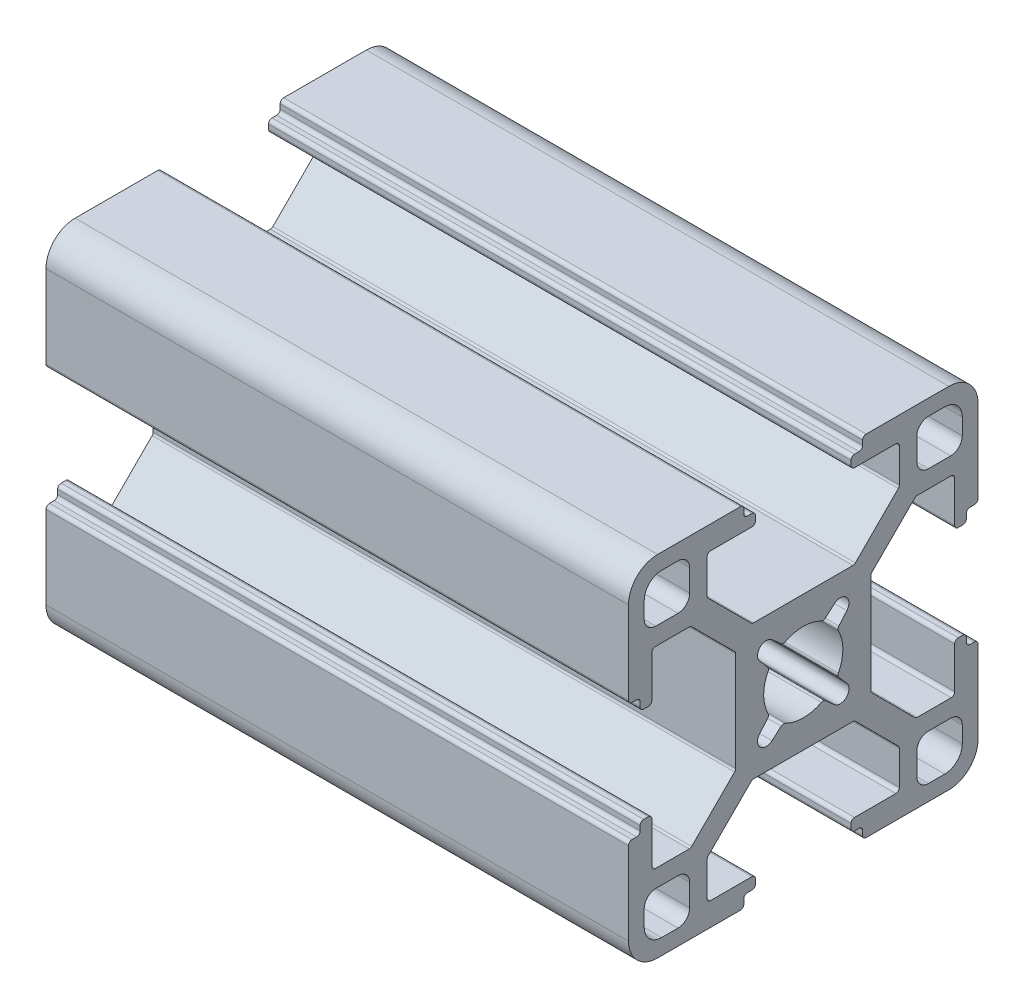
from build123d import *

# Parameters (mm, degrees)
BOSS_EXTRUDE1_DEPTH = 50


with BuildPart() as part:
    # Sketch1 → Boss-Extrude1 (new body)
    with BuildSketch(Plane(origin=(0, 0, 0), x_dir=(0, 0, -1), z_dir=(1, 0, 0))):
        with BuildLine():
            Line((-8.25, 9.788477631), (-8.25, 12.7))
            ThreePointArc((-8.25, 12.7), (-8.162132034, 12.912132034), (-7.95, 13))
            Line((-7.95, 13), (-4.4, 13))
            ThreePointArc((-4.4, 13), (-4.187867966, 13.087867966), (-4.1, 13.3))
            Line((-4.1, 13.3), (-4.1, 13.7))
            ThreePointArc((-4.1, 13.7), (-4.187867966, 13.912132034), (-4.4, 14))
            Line((-4.4, 14), (-4.8, 14))
            ThreePointArc((-4.8, 14), (-5.012132034, 14.087867966), (-5.1, 14.3))
            Line((-5.1, 14.3), (-5.1, 14.7))
            ThreePointArc((-5.1, 14.7), (-5.187867966, 14.912132034), (-5.4, 15))
            Line((-5.4, 15), (-12.5, 15))
            ThreePointArc((-12.5, 15), (-14.267766953, 14.267766953), (-15, 12.5))
            Line((-15, 12.5), (-15, 5.4))
            ThreePointArc((-15, 5.4), (-14.912132034, 5.187867966), (-14.7, 5.1))
            Line((-14.7, 5.1), (-14.3, 5.1))
            ThreePointArc((-14.3, 5.1), (-14.087867966, 5.012132034), (-14, 4.8))
            Line((-14, 4.8), (-14, 4.4))
            ThreePointArc((-14, 4.4), (-13.912132034, 4.187867966), (-13.7, 4.1))
            Line((-13.7, 4.1), (-13.3, 4.1))
            ThreePointArc((-13.3, 4.1), (-13.087867966, 4.187867966), (-13, 4.4))
            Line((-13, 4.4), (-13, 7.95))
            ThreePointArc((-13, 7.95), (-12.912132034, 8.162132034), (-12.7, 8.25))
            Line((-12.7, 8.25), (-9.788477631, 8.25))
            ThreePointArc((-9.788477631, 8.25), (-9.673672601, 8.22716386), (-9.576345597, 8.162132034))
            Line((-9.576345597, 8.162132034), (-5.887867966, 4.473654403))
            ThreePointArc((-5.887867966, 4.473654403), (-5.82283614, 4.376327399), (-5.8, 4.261522369))
            Line((-5.8, 4.261522369), (-5.8, -4.261522369))
            ThreePointArc((-5.8, -4.261522369), (-5.82283614, -4.376327399), (-5.887867966, -4.473654403))
            Line((-5.887867966, -4.473654403), (-9.576345597, -8.162132034))
            ThreePointArc((-9.576345597, -8.162132034), (-9.673672601, -8.22716386), (-9.788477631, -8.25))
            Line((-9.788477631, -8.25), (-12.7, -8.25))
            ThreePointArc((-12.7, -8.25), (-12.912132034, -8.162132034), (-13, -7.95))
            Line((-13, -7.95), (-13, -4.4))
            ThreePointArc((-13, -4.4), (-13.087867966, -4.187867966), (-13.3, -4.1))
            Line((-13.3, -4.1), (-13.7, -4.1))
            ThreePointArc((-13.7, -4.1), (-13.912132034, -4.187867966), (-14, -4.4))
            Line((-14, -4.4), (-14, -4.8))
            ThreePointArc((-14, -4.8), (-14.087867966, -5.012132034), (-14.3, -5.1))
            Line((-14.3, -5.1), (-14.7, -5.1))
            ThreePointArc((-14.7, -5.1), (-14.912132034, -5.187867966), (-15, -5.4))
            Line((-15, -5.4), (-15, -12.5))
            ThreePointArc((-15, -12.5), (-14.267766953, -14.267766953), (-12.5, -15))
            Line((-12.5, -15), (-5.4, -15))
            ThreePointArc((-5.4, -15), (-5.187867966, -14.912132034), (-5.1, -14.7))
            Line((-5.1, -14.7), (-5.1, -14.3))
            ThreePointArc((-5.1, -14.3), (-5.012132034, -14.087867966), (-4.8, -14))
            Line((-4.8, -14), (-4.4, -14))
            ThreePointArc((-4.4, -14), (-4.187867966, -13.912132034), (-4.1, -13.7))
            Line((-4.1, -13.7), (-4.1, -13.3))
            ThreePointArc((-4.1, -13.3), (-4.187867966, -13.087867966), (-4.4, -13))
            Line((-4.4, -13), (-7.95, -13))
            ThreePointArc((-7.95, -13), (-8.162132034, -12.912132034), (-8.25, -12.7))
            Line((-8.25, -12.7), (-8.25, -9.788477631))
            ThreePointArc((-8.25, -9.788477631), (-8.22716386, -9.673672601), (-8.162132034, -9.576345597))
            Line((-8.162132034, -9.576345597), (-4.473654403, -5.887867966))
            ThreePointArc((-4.473654403, -5.887867966), (-4.376327399, -5.82283614), (-4.261522369, -5.8))
            Line((-4.261522369, -5.8), (4.261522369, -5.8))
            ThreePointArc((4.261522369, -5.8), (4.376327399, -5.82283614), (4.473654403, -5.887867966))
            Line((4.473654403, -5.887867966), (8.162132034, -9.576345597))
            ThreePointArc((8.162132034, -9.576345597), (8.22716386, -9.673672601), (8.25, -9.788477631))
            Line((8.25, -9.788477631), (8.25, -12.7))
            ThreePointArc((8.25, -12.7), (8.162132034, -12.912132034), (7.95, -13))
            Line((7.95, -13), (4.4, -13))
            ThreePointArc((4.4, -13), (4.187867966, -13.087867966), (4.1, -13.3))
            Line((4.1, -13.3), (4.1, -13.7))
            ThreePointArc((4.1, -13.7), (4.187867966, -13.912132034), (4.4, -14))
            Line((4.4, -14), (4.8, -14))
            ThreePointArc((4.8, -14), (5.012132034, -14.087867966), (5.1, -14.3))
            Line((5.1, -14.3), (5.1, -14.7))
            ThreePointArc((5.1, -14.7), (5.187867966, -14.912132034), (5.4, -15))
            Line((5.4, -15), (12.5, -15))
            ThreePointArc((12.5, -15), (14.267766953, -14.267766953), (15, -12.5))
            Line((15, -12.5), (15, -5.4))
            ThreePointArc((15, -5.4), (14.912132034, -5.187867966), (14.7, -5.1))
            Line((14.7, -5.1), (14.3, -5.1))
            ThreePointArc((14.3, -5.1), (14.087867966, -5.012132034), (14, -4.8))
            Line((14, -4.8), (14, -4.4))
            ThreePointArc((14, -4.4), (13.912132034, -4.187867966), (13.7, -4.1))
            Line((13.7, -4.1), (13.3, -4.1))
            ThreePointArc((13.3, -4.1), (13.087867966, -4.187867966), (13, -4.4))
            Line((13, -4.4), (13, -7.95))
            ThreePointArc((13, -7.95), (12.912132034, -8.162132034), (12.7, -8.25))
            Line((12.7, -8.25), (9.788477631, -8.25))
            ThreePointArc((9.788477631, -8.25), (9.673672601, -8.22716386), (9.576345597, -8.162132034))
            Line((9.576345597, -8.162132034), (5.887867966, -4.473654403))
            ThreePointArc((5.887867966, -4.473654403), (5.82283614, -4.376327399), (5.8, -4.261522369))
            Line((5.8, -4.261522369), (5.8, 4.261522369))
            ThreePointArc((5.8, 4.261522369), (5.82283614, 4.376327399), (5.887867966, 4.473654403))
            Line((5.887867966, 4.473654403), (9.576345597, 8.162132034))
            ThreePointArc((9.576345597, 8.162132034), (9.673672601, 8.22716386), (9.788477631, 8.25))
            Line((9.788477631, 8.25), (12.7, 8.25))
            ThreePointArc((12.7, 8.25), (12.912132034, 8.162132034), (13, 7.95))
            Line((13, 7.95), (13, 4.4))
            ThreePointArc((13, 4.4), (13.087867966, 4.187867966), (13.3, 4.1))
            Line((13.3, 4.1), (13.7, 4.1))
            ThreePointArc((13.7, 4.1), (13.912132034, 4.187867966), (14, 4.4))
            Line((14, 4.4), (14, 4.8))
            ThreePointArc((14, 4.8), (14.087867966, 5.012132034), (14.3, 5.1))
            Line((14.3, 5.1), (14.7, 5.1))
            ThreePointArc((14.7, 5.1), (14.912132034, 5.187867966), (15, 5.4))
            Line((15, 5.4), (15, 12.5))
            ThreePointArc((15, 12.5), (14.267766953, 14.267766953), (12.5, 15))
            Line((12.5, 15), (5.4, 15))
            ThreePointArc((5.4, 15), (5.187867966, 14.912132034), (5.1, 14.7))
            Line((5.1, 14.7), (5.1, 14.3))
            ThreePointArc((5.1, 14.3), (5.012132034, 14.087867966), (4.8, 14))
            Line((4.8, 14), (4.4, 14))
            ThreePointArc((4.4, 14), (4.187867966, 13.912132034), (4.1, 13.7))
            Line((4.1, 13.7), (4.1, 13.3))
            ThreePointArc((4.1, 13.3), (4.187867966, 13.087867966), (4.4, 13))
            Line((4.4, 13), (7.95, 13))
            ThreePointArc((7.95, 13), (8.162132034, 12.912132034), (8.25, 12.7))
            Line((8.25, 12.7), (8.25, 9.788477631))
            ThreePointArc((8.25, 9.788477631), (8.22716386, 9.673672601), (8.162132034, 9.576345597))
            Line((8.162132034, 9.576345597), (4.473654403, 5.887867966))
            ThreePointArc((4.473654403, 5.887867966), (4.376327399, 5.82283614), (4.261522369, 5.8))
            Line((4.261522369, 5.8), (-4.261522369, 5.8))
            ThreePointArc((-4.261522369, 5.8), (-4.376327399, 5.82283614), (-4.473654403, 5.887867966))
            Line((-4.473654403, 5.887867966), (-8.162132034, 9.576345597))
            ThreePointArc((-8.162132034, 9.576345597), (-8.22716386, 9.673672601), (-8.25, 9.788477631))
        make_face()
        with BuildLine():
            Line((3.05514787, -1.904659815), (3.741964502, -2.698343541))
            ThreePointArc((3.741964502, -2.698343541), (3.70396732, -3.720635173), (2.68151539, -3.75404201))
            Line((2.68151539, -3.75404201), (1.890923385, -3.06366876))
            ThreePointArc((1.890923385, -3.06366876), (1.729867527, -2.991839768), (1.556279141, -3.022911715))
            ThreePointArc((1.556279141, -3.022911715), (0, -3.4), (-1.55627914, -3.022911715))
            ThreePointArc((-1.55627914, -3.022911715), (-1.729867526, -2.991839768), (-1.890923385, -3.06366876))
            Line((-1.890923385, -3.06366876), (-2.68151539, -3.75404201))
            ThreePointArc((-2.68151539, -3.75404201), (-3.70396732, -3.720635173), (-3.741964502, -2.698343541))
            Line((-3.741964502, -2.698343541), (-3.05514787, -1.904659815))
            ThreePointArc((-3.05514787, -1.904659815), (-2.984042722, -1.743283077), (-3.015893746, -1.56983595))
            ThreePointArc((-3.015893746, -1.56983595), (-3.4, 0), (-3.015893746, 1.56983595))
            ThreePointArc((-3.015893746, 1.56983595), (-2.984042722, 1.743283077), (-3.05514787, 1.904659815))
            Line((-3.05514787, 1.904659815), (-3.741964502, 2.698343541))
            ThreePointArc((-3.741964502, 2.698343541), (-3.70396732, 3.720635173), (-2.68151539, 3.75404201))
            Line((-2.68151539, 3.75404201), (-1.890923385, 3.06366876))
            ThreePointArc((-1.890923385, 3.06366876), (-1.729867526, 2.991839768), (-1.55627914, 3.022911715))
            ThreePointArc((-1.55627914, 3.022911715), (0, 3.4), (1.556279141, 3.022911715))
            ThreePointArc((1.556279141, 3.022911715), (1.729867527, 2.991839768), (1.890923385, 3.06366876))
            Line((1.890923385, 3.06366876), (2.68151539, 3.75404201))
            ThreePointArc((2.68151539, 3.75404201), (3.70396732, 3.720635173), (3.741964502, 2.698343541))
            Line((3.741964502, 2.698343541), (3.05514787, 1.904659815))
            ThreePointArc((3.05514787, 1.904659815), (2.984042722, 1.743283077), (3.015893747, 1.56983595))
            ThreePointArc((3.015893747, 1.56983595), (3.4, 0), (3.015893747, -1.56983595))
            ThreePointArc((3.015893747, -1.56983595), (2.984042722, -1.743283077), (3.05514787, -1.904659815))
        make_face(mode=Mode.SUBTRACT)
        with BuildLine():
            Line((10.75, -9.75), (12.65, -9.75))
            ThreePointArc((12.65, -9.75), (13.357106781, -10.042893219), (13.65, -10.75))
            Line((13.65, -10.75), (13.65, -12.15))
            ThreePointArc((13.65, -12.15), (13.210660172, -13.210660172), (12.15, -13.65))
            Line((12.15, -13.65), (10.75, -13.65))
            ThreePointArc((10.75, -13.65), (10.042893219, -13.357106781), (9.75, -12.65))
            Line((9.75, -12.65), (9.75, -10.75))
            ThreePointArc((9.75, -10.75), (10.042893219, -10.042893219), (10.75, -9.75))
        make_face(mode=Mode.SUBTRACT)
        with BuildLine():
            Line((-10.75, 9.75), (-12.65, 9.75))
            ThreePointArc((-12.65, 9.75), (-13.357106781, 10.042893219), (-13.65, 10.75))
            Line((-13.65, 10.75), (-13.65, 12.15))
            ThreePointArc((-13.65, 12.15), (-13.210660172, 13.210660172), (-12.15, 13.65))
            Line((-12.15, 13.65), (-10.75, 13.65))
            ThreePointArc((-10.75, 13.65), (-10.042893219, 13.357106781), (-9.75, 12.65))
            Line((-9.75, 12.65), (-9.75, 10.75))
            ThreePointArc((-9.75, 10.75), (-10.042893219, 10.042893219), (-10.75, 9.75))
        make_face(mode=Mode.SUBTRACT)
        with BuildLine():
            Line((9.75, 10.75), (9.75, 12.65))
            ThreePointArc((9.75, 12.65), (10.042893219, 13.357106781), (10.75, 13.65))
            Line((10.75, 13.65), (12.15, 13.65))
            ThreePointArc((12.15, 13.65), (13.210660172, 13.210660172), (13.65, 12.15))
            Line((13.65, 12.15), (13.65, 10.75))
            ThreePointArc((13.65, 10.75), (13.357106781, 10.042893219), (12.65, 9.75))
            Line((12.65, 9.75), (10.75, 9.75))
            ThreePointArc((10.75, 9.75), (10.042893219, 10.042893219), (9.75, 10.75))
        make_face(mode=Mode.SUBTRACT)
        with BuildLine():
            Line((-9.75, -10.75), (-9.75, -12.65))
            ThreePointArc((-9.75, -12.65), (-10.042893219, -13.357106781), (-10.75, -13.65))
            Line((-10.75, -13.65), (-12.15, -13.65))
            ThreePointArc((-12.15, -13.65), (-13.210660172, -13.210660172), (-13.65, -12.15))
            Line((-13.65, -12.15), (-13.65, -10.75))
            ThreePointArc((-13.65, -10.75), (-13.357106781, -10.042893219), (-12.65, -9.75))
            Line((-12.65, -9.75), (-10.75, -9.75))
            ThreePointArc((-10.75, -9.75), (-10.042893219, -10.042893219), (-9.75, -10.75))
        make_face(mode=Mode.SUBTRACT)
    extrude(amount=BOSS_EXTRUDE1_DEPTH)


solid = part.part
